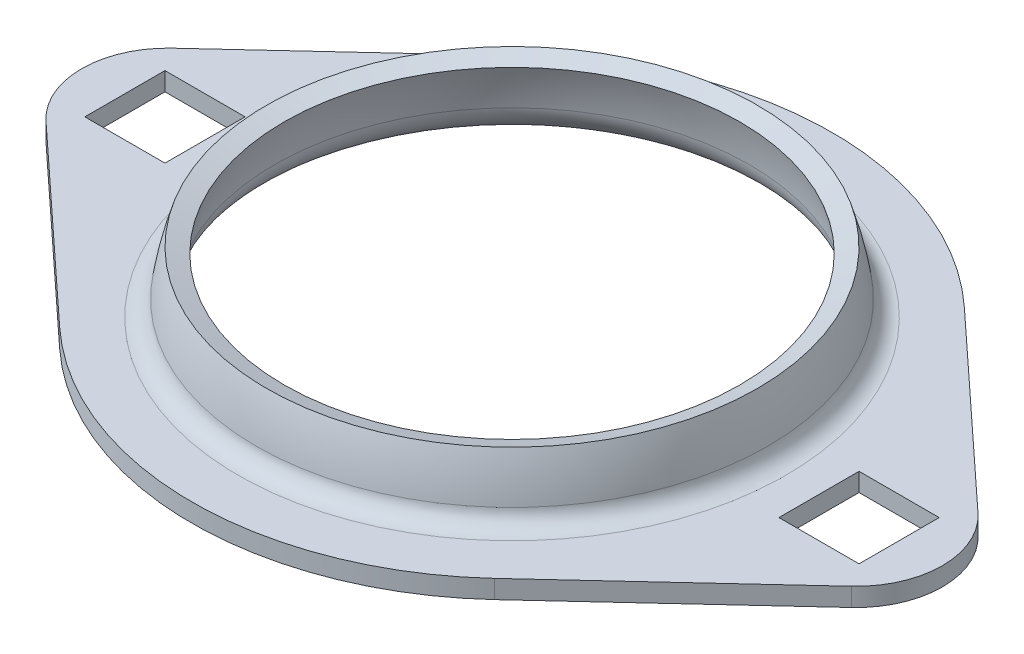
from build123d import *

# Parameters (mm, degrees)
THICKEN_1_T2        = 2
SKETCH_2_R          = 29.732137495
EXTRUDE_1_DEPTH     = 2
SKETCH_2_3_W        = 8.7
SKETCH_2_3_H        = 8.7
CUT_EXTRUDE_1_DEPTH = 59.86436084


with BuildPart() as body_1:
    # Sheet Revolve 1: a surface, the sketch's curves turned about an axis
    with BuildLine(Plane.XY, mode=Mode.PRIVATE) as sheet_revolve_1_1_path:
        Line((34.75, 8.5), (29.732137495, 8.5))
        ThreePointArc((29.732137495, 8.5), (27.09901514, 9.488909389), (25.767852495, 11.966666667))
        ThreePointArc((25.767852495, 11.966666667), (25.354764169, 14.256382016), (24.738633754, 16.5))
    sheet_revolve_1_1 = Shell.revolve(sheet_revolve_1_1_path.wire(), 360, Axis((0, 50, 0), (0, -1, 0)))
    add(Solid.thicken(sheet_revolve_1_1, -THICKEN_1_T2))

    # Sketch 2 → Extrude 1 (add)
    with BuildSketch(Plane.XZ.offset(-8.5)):
        with BuildLine():
            Line((-23.614933424, 25.493085717), (-43.727741416, 6.862048778))
            ThreePointArc((-43.727741416, 6.862048778), (-46.725, 0), (-43.727741416, -6.862048778))
            Line((-43.727741416, -6.862048778), (-23.614933424, -25.493085717))
            ThreePointArc((-23.614933424, -25.493085717), (0, -34.75), (23.614933424, -25.493085717))
            Line((23.614933424, -25.493085717), (43.727741416, -6.862048778))
            ThreePointArc((43.727741416, -6.862048778), (46.725, 0), (43.727741416, 6.862048778))
            Line((43.727741416, 6.862048778), (23.614933424, 25.493085717))
            ThreePointArc((23.614933424, 25.493085717), (0, 34.75), (-23.614933424, 25.493085717))
        make_face()
        Circle(SKETCH_2_R, mode=Mode.SUBTRACT)
    extrude(amount=-EXTRUDE_1_DEPTH)

    # Sketch 2_3 → Cut-Extrude 1 (cut, through all)
    with BuildSketch(Plane.XZ.offset(-8.5)):
        with Locations((-37.675, 0)):
            Rectangle(SKETCH_2_3_W, SKETCH_2_3_H)
        with Locations((37.675, 0)):
            Rectangle(SKETCH_2_3_W, SKETCH_2_3_H)
    extrude(amount=-CUT_EXTRUDE_1_DEPTH, mode=Mode.SUBTRACT)


solid = body_1.part
